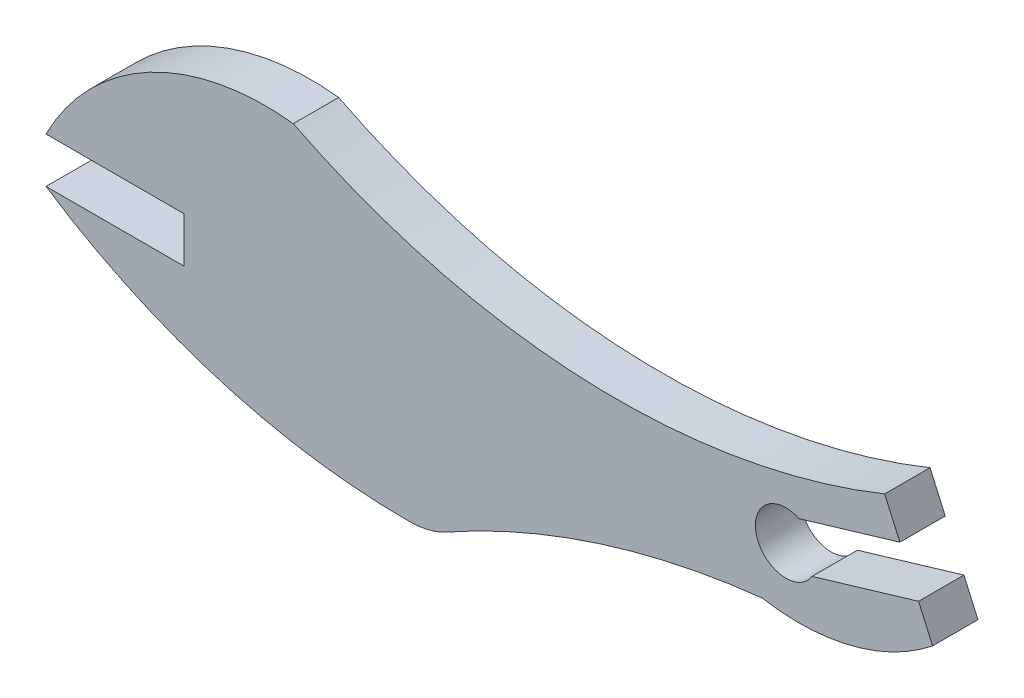
from build123d import *

# Parameters (mm, degrees)
BOSS_EXTRUDE1_DEPTH = 1.524


with BuildPart() as part:
    # Sketch1 → Boss-Extrude1 (new body)
    with BuildSketch(Plane.XY):
        with BuildLine():
            Line((4.36034561, 0), (4.36034561, -1.524))
            Line((4.36034561, -1.524), (-0.270041396, -1.524))
            ThreePointArc((-0.270041396, -1.524), (5.57790397, -4.249042789), (11.964164328, -5.165558929))
            ThreePointArc((11.964164328, -5.165558929), (12.599243088, -5.082111381), (13.193252116, -4.842441192))
            ThreePointArc((13.193252116, -4.842441192), (18.3130715, -2.621767508), (23.773581772, -1.469912607))
            ThreePointArc((23.773581772, -1.469912607), (26.795642109, -1.350433231), (29.50183022, 0))
            Line((29.50183022, 0), (29.028606423, 1.061962035))
            Line((29.028606423, 1.061962035), (25.453006053, -0.002386196))
            ThreePointArc((25.453006053, -0.002386196), (23.593059825, 0.239006946), (25.018211481, 1.458274504))
            Line((25.018211481, 1.458274504), (28.403024501, 2.465831103))
            Line((28.403024501, 2.465831103), (27.891133112, 3.614567125))
            ThreePointArc((27.891133112, 3.614567125), (17.871956928, 1.891446971), (8.033839359, 4.453570535))
            ThreePointArc((8.033839359, 4.453570535), (3.185317895, 3.52559175), (-0.270041396, 0))
            Line((-0.270041396, 0), (4.36034561, 0))
        make_face()
    extrude(amount=BOSS_EXTRUDE1_DEPTH)


solid = part.part
